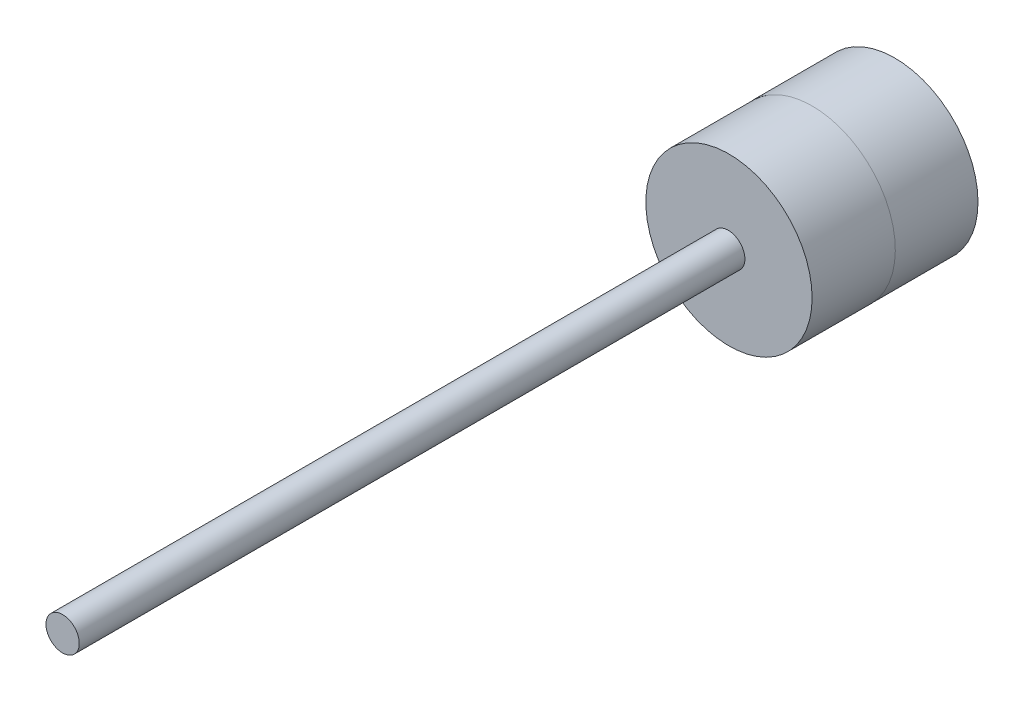
from build123d import *

# Parameters (mm, degrees)
SKETCH8_R           = 5
BOSS_EXTRUDE3_DEPTH = 5
SKETCH9_R           = 4.996260813
BOSS_EXTRUDE4_DEPTH = 5
SKETCH10_R          = 1
BOSS_EXTRUDE5_DEPTH = 40


with BuildPart() as part:
    # Sketch8 → Boss-Extrude3 (new body)
    with BuildSketch(Plane.XY):
        with Locations((-48.452108999, 26.292732134)):
            Circle(SKETCH8_R)
        with BuildLine():
            Line((-46.454907961, 26.292732134), (-46.454907961, 27.796456848))
            ThreePointArc((-46.454907961, 27.796456848), (-50.952108999, 26.292732134), (-46.454907961, 24.789007421))
            Line((-46.454907961, 24.789007421), (-46.454907961, 26.292732134))
        make_face(mode=Mode.SUBTRACT)
    extrude(amount=BOSS_EXTRUDE3_DEPTH)

    # Sketch9 → Boss-Extrude4 (add)
    with BuildSketch(Plane.XY.offset(5)):
        with Locations((-48.416448045, 26.317478542)):
            Circle(SKETCH9_R)
    extrude(amount=BOSS_EXTRUDE4_DEPTH)

    # Sketch10 → Boss-Extrude5 (add)
    with BuildSketch(Plane.XY.offset(10)):
        with Locations((-48.460247299, 26.321784668)):
            Circle(SKETCH10_R)
    extrude(amount=BOSS_EXTRUDE5_DEPTH)


solid = part.part
